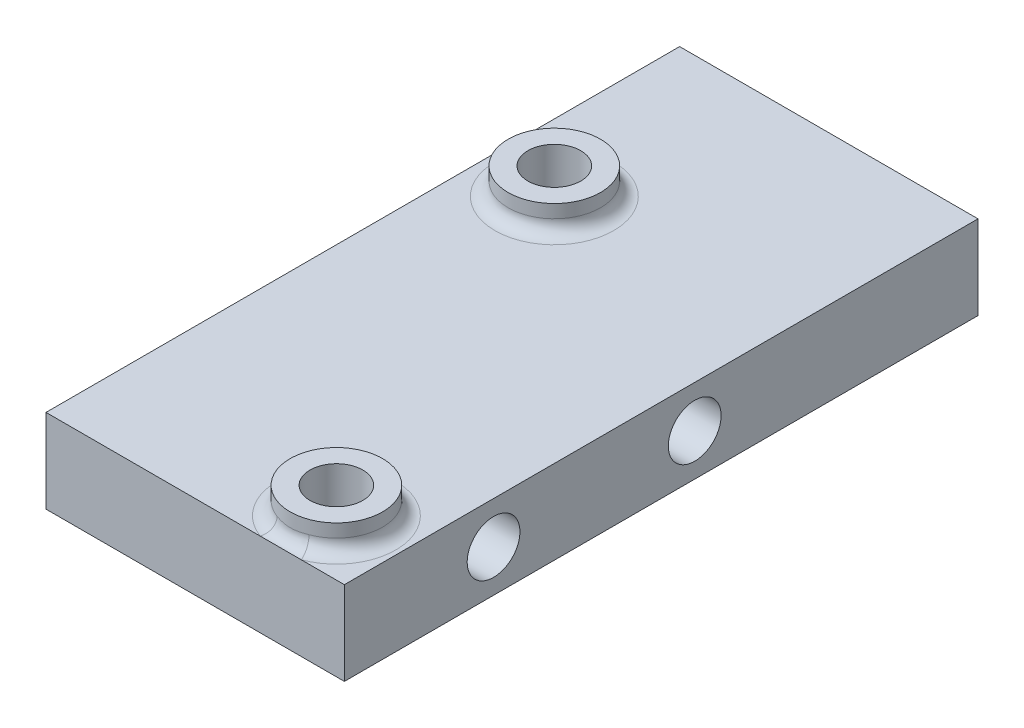
from build123d import *

# Parameters (mm, degrees)
SKETCH1_W           = 22.606
SKETCH1_H           = 48.006
SKETCH1_R           = 2
BOSS_EXTRUDE1_DEPTH = 6.35
SKETCH2_R           = 2
CUT_EXTRUDE1_DEPTH  = 23.606
SKETCH3_R           = 3.5
SKETCH3_R_2         = 2
BOSS_EXTRUDE2_DEPTH = 2
FILLET1_R           = 1


with BuildPart() as part:
    # Sketch1 → Boss-Extrude1 (new body)
    with BuildSketch(Plane(origin=(0, 0, 0), x_dir=(1, 0, 0), z_dir=(0, 1, 0))):
        with Locations((11.43, 24.13)):
            Rectangle(SKETCH1_W, SKETCH1_H)
        with Locations((5.207, 33.55975)):
            Circle(SKETCH1_R, mode=Mode.SUBTRACT)
        with Locations((17.907, 4.34975)):
            Circle(SKETCH1_R, mode=Mode.SUBTRACT)
    extrude(amount=BOSS_EXTRUDE1_DEPTH)

    # Sketch2 → Cut-Extrude1 (cut, through all)
    with BuildSketch(Plane.ZY.offset(-0.127)):
        with Locations((-26.67, 3.175)):
            Circle(SKETCH2_R)
        with Locations((-11.43, 3.175)):
            Circle(SKETCH2_R)
    extrude(amount=-CUT_EXTRUDE1_DEPTH, mode=Mode.SUBTRACT)

    # Sketch3 → Boss-Extrude2 (add)
    with BuildSketch(Plane(origin=(0, 6.35, 0), x_dir=(1, 0, 0), z_dir=(0, 1, 0))):
        with Locations((5.207, 33.55975)):
            Circle(SKETCH3_R)
        with Locations((5.207, 33.55975)):
            Circle(SKETCH3_R_2, mode=Mode.SUBTRACT)
        with Locations((17.907, 4.34975)):
            Circle(SKETCH3_R)
        with Locations((17.907, 4.34975)):
            Circle(SKETCH3_R_2, mode=Mode.SUBTRACT)
    extrude(amount=BOSS_EXTRUDE2_DEPTH)

    # Fillet1
    fillet1_edges = [part.edges().sort_by_distance(p)[0] for p in [
        (1.707, 6.35, -33.55975),
        (14.407, 6.35, -4.34975),
    ]]
    fillet(fillet1_edges, radius=FILLET1_R)


solid = part.part
